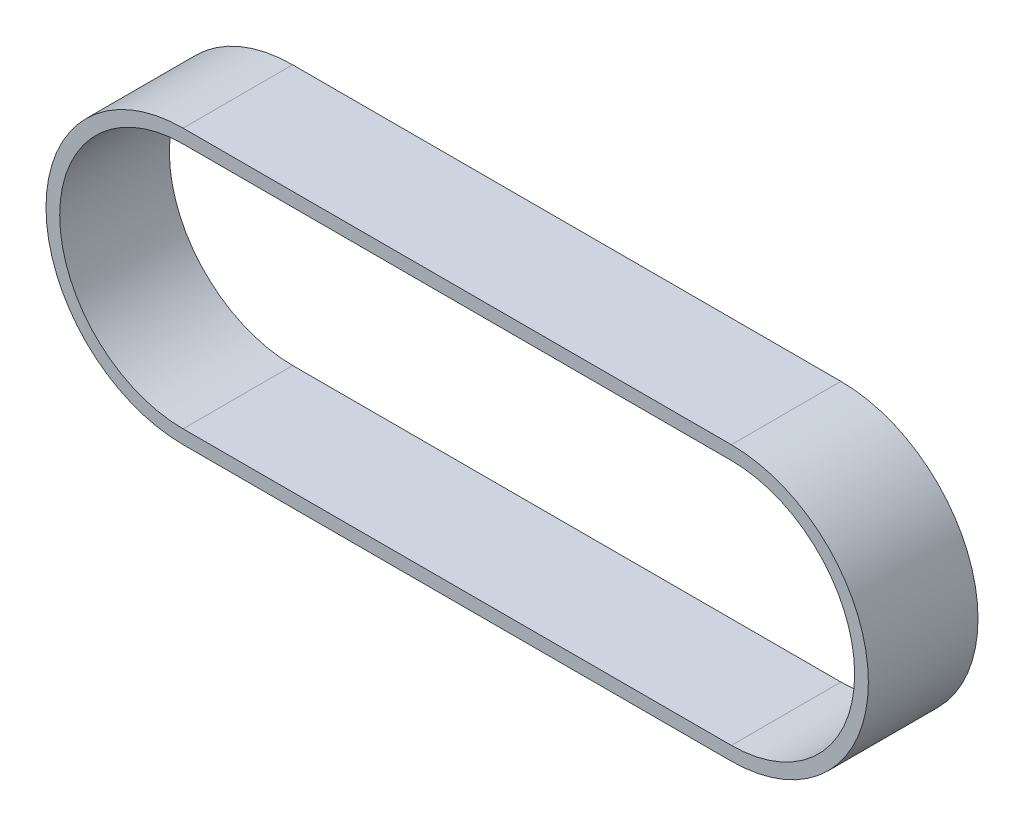
from build123d import *

# Parameters (mm, degrees)
BOSS_EXTRUDE1_DEPTH = 20


with BuildPart() as part:
    # Sketch1 → Boss-Extrude1 (new body)
    with BuildSketch(Plane.XY):
        with BuildLine():
            Line((-50, 25), (50, 25))
            ThreePointArc((50, 25), (75, 0), (50, -25))
            Line((50, -25), (-50, -25))
            ThreePointArc((-50, -25), (-75, 0), (-50, 25))
        make_face()
        with BuildLine():
            Line((-50, 22.5), (50, 22.5))
            ThreePointArc((50, 22.5), (72.5, 0), (50, -22.5))
            Line((50, -22.5), (-50, -22.5))
            ThreePointArc((-50, -22.5), (-72.5, 0), (-50, 22.5))
        make_face(mode=Mode.SUBTRACT)
    extrude(amount=BOSS_EXTRUDE1_DEPTH)


solid = part.part
